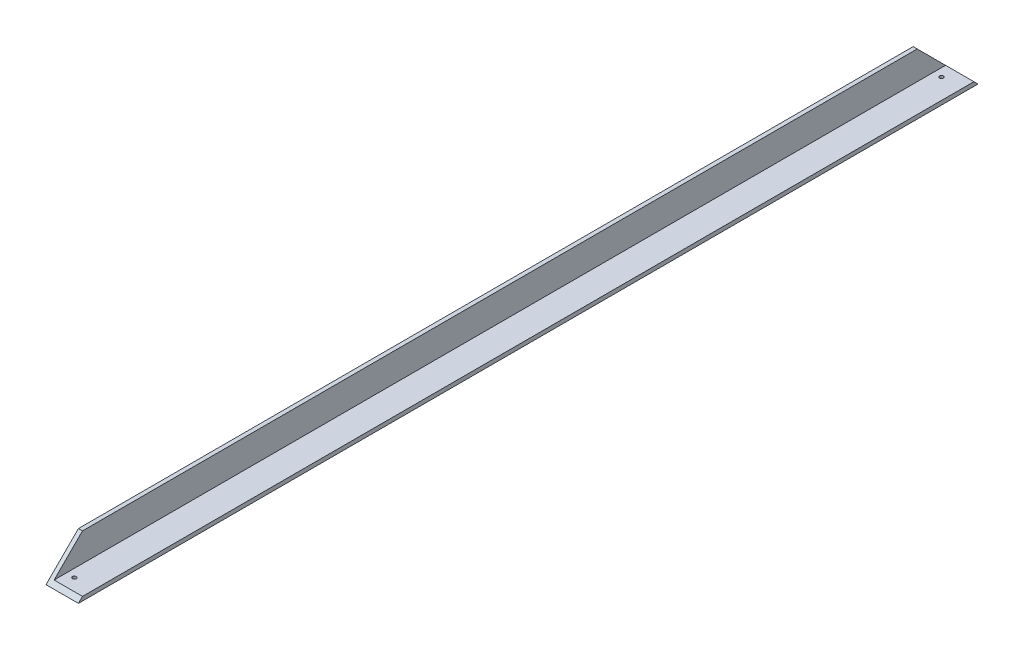
from build123d import *

# Parameters (mm, degrees)
BOSS_EXTRUDE1_DEPTH = 704.85
CUT_EXTRUDE1_DEPTH  = 711.2
SKETCH3_R           = 1.5
CUT_EXTRUDE2_DEPTH  = 711.2


with BuildPart() as part:
    # Sketch1 → Boss-Extrude1 (new body)
    with BuildSketch(Plane.XY):
        Polygon((0, 25.4), (0, 0), (25.4, 0), (25.4, 3.175), (3.175, 3.175), (3.175, 25.4), align=None)
    extrude(amount=BOSS_EXTRUDE1_DEPTH)

    # Sketch2 → Cut-Extrude1 (cut)
    with BuildSketch(Plane.ZY):
        Polygon((0, 8.542079309), (0, 0), (25.4, 25.4), (0, 25.4), align=None)
        Polygon((704.85, 25.4), (679.45, 25.4), (704.85, 0), align=None)
    extrude(amount=-CUT_EXTRUDE1_DEPTH, mode=Mode.SUBTRACT)

    # Sketch3 → Cut-Extrude2 (cut)
    with BuildSketch(Plane.XZ):
        with Locations((9.525, 692.15)):
            Circle(SKETCH3_R)
        with Locations((9.525, 12.7)):
            Circle(SKETCH3_R)
    extrude(amount=-CUT_EXTRUDE2_DEPTH, mode=Mode.SUBTRACT)


solid = part.part
